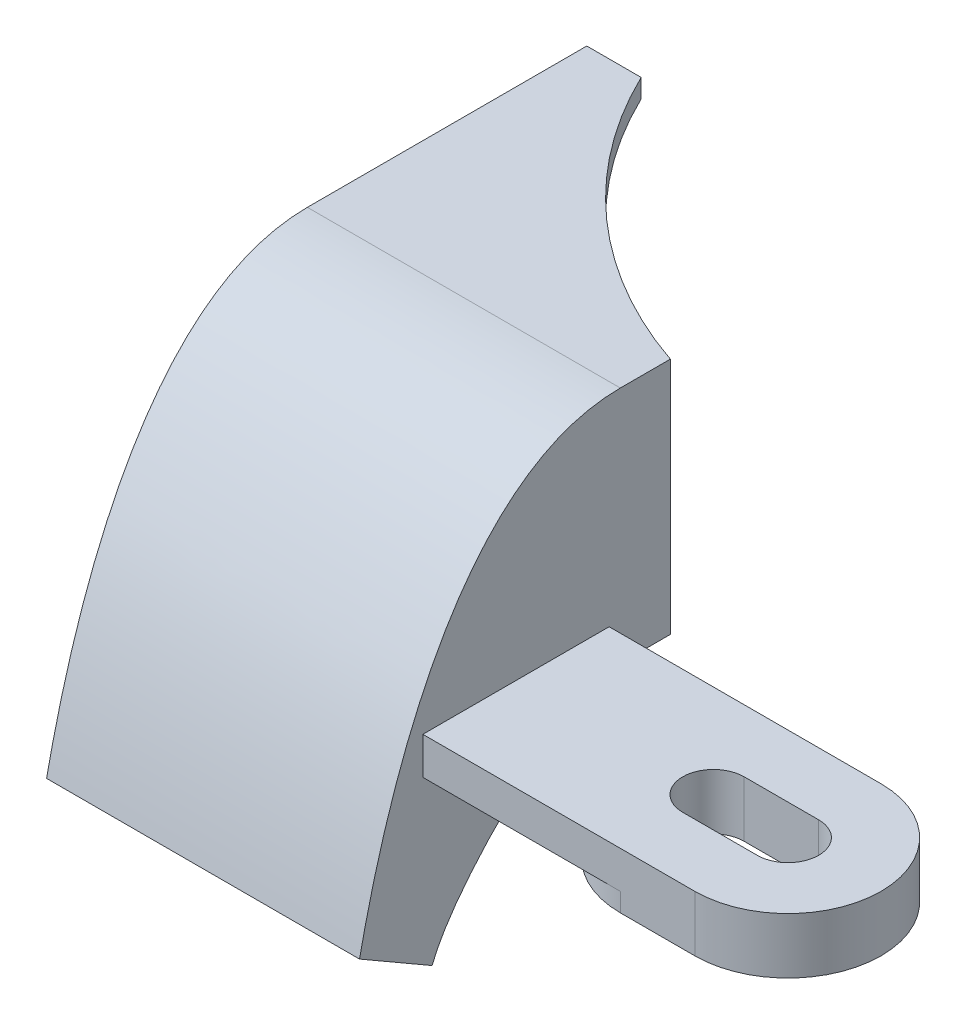
from build123d import *

# Parameters (mm, degrees)
ESBO_O1_W                = 16.8
ESBO_O1_H                = 12.8
RESSALTO_EXTRUS_O1_DEPTH = 15
RESSALTO_EXTRUS_O2_DEPTH = 16.8
CASCA1_T                 = -1
ESBO_O5_R                = 24
CORTE_EXTRUS_O1_DEPTH    = 22.8000001
RESSALTO_EXTRUS_O3_DEPTH = 2
RESSALTO_EXTRUS_O4_DEPTH = 1


with BuildPart() as part:
    # Esboço1 → Ressalto-extrusão1 (new body)
    with BuildSketch(Plane.XY):
        Rectangle(ESBO_O1_W, ESBO_O1_H)
    extrude(amount=RESSALTO_EXTRUS_O1_DEPTH)

    # Esboço2 → Ressalto-extrusão2 (add, through all)
    with BuildSketch(Plane(origin=(8.4, 0, 0), x_dir=(0, 0, -1), z_dir=(1, 0, 0))):
        with BuildLine():
            Line((-25.102885683, -15.4), (-29, -13.15))
            add(Edge.make_bspline(
                [(-15, 6.4), (-24.5700068, 6.4), (-28.06930524, -8.749171672), (-29, -13.15)],
                knots=[0, 0, 0, 0, 1, 1, 1, 1], degree=3))
            Line((-15, 6.4), (-15, -6.4))
            add(Edge.make_bspline(
                [(-15, -6.4), (-18.032161103, -6.4), (-23.944769552, -12.297903221), (-25.102885683, -15.4)],
                knots=[0, 0, 0, 0, 1, 1, 1, 1], degree=3))
        make_face()
    extrude(amount=-RESSALTO_EXTRUS_O2_DEPTH)

    # Casca1
    casca1_openings = [part.faces().sort_by_distance(p)[0] for p in [
        (0, -14.275, 27.051442841),
        (0, 0, 0),
    ]]
    offset(amount=CASCA1_T, openings=casca1_openings)

    # Esboço5 → Corte-extrusão1 (cut, through all)
    with BuildSketch(Plane(origin=(0, 6.4, 0), x_dir=(1, 0, 0), z_dir=(0, 1, 0))):
        with Locations((16.15, 10.4)):
            Circle(ESBO_O5_R)
    extrude(amount=-CORTE_EXTRUS_O1_DEPTH, mode=Mode.SUBTRACT)

    # Esboço6 → Ressalto-extrusão3 (add)
    with BuildSketch(Plane.XZ.offset(6.4)):
        with BuildLine():
            Line((23, 25.6), (8.4, 25.6))
            Line((8.4, 25.6), (8.4, 15.6))
            Line((8.4, 15.6), (23, 15.6))
            ThreePointArc((23, 15.6), (28, 20.6), (23, 25.6))
        make_face()
        with BuildLine():
            Line((19, 22.25), (23, 22.25))
            ThreePointArc((23, 22.25), (24.65, 20.6), (23, 18.95))
            Line((23, 18.95), (19, 18.95))
            ThreePointArc((19, 18.95), (17.35, 20.6), (19, 22.25))
        make_face(mode=Mode.SUBTRACT)
    extrude(amount=-RESSALTO_EXTRUS_O3_DEPTH)

    # Esboço7 → Ressalto-extrusão4 (add)
    with BuildSketch(Plane.XZ.offset(6.4)):
        with BuildLine():
            Line((19, 25.6), (23, 25.6))
            ThreePointArc((23, 25.6), (28, 20.6), (23, 15.6))
            Line((23, 15.6), (19, 15.6))
            ThreePointArc((19, 15.6), (14, 20.6), (19, 25.6))
        make_face()
        with BuildLine():
            Line((19, 18.95), (23, 18.95))
            ThreePointArc((23, 18.95), (24.65, 20.6), (23, 22.25))
            Line((23, 22.25), (19, 22.25))
            ThreePointArc((19, 22.25), (17.35, 20.6), (19, 18.95))
        make_face(mode=Mode.SUBTRACT)
    extrude(amount=RESSALTO_EXTRUS_O4_DEPTH)


solid = part.part
